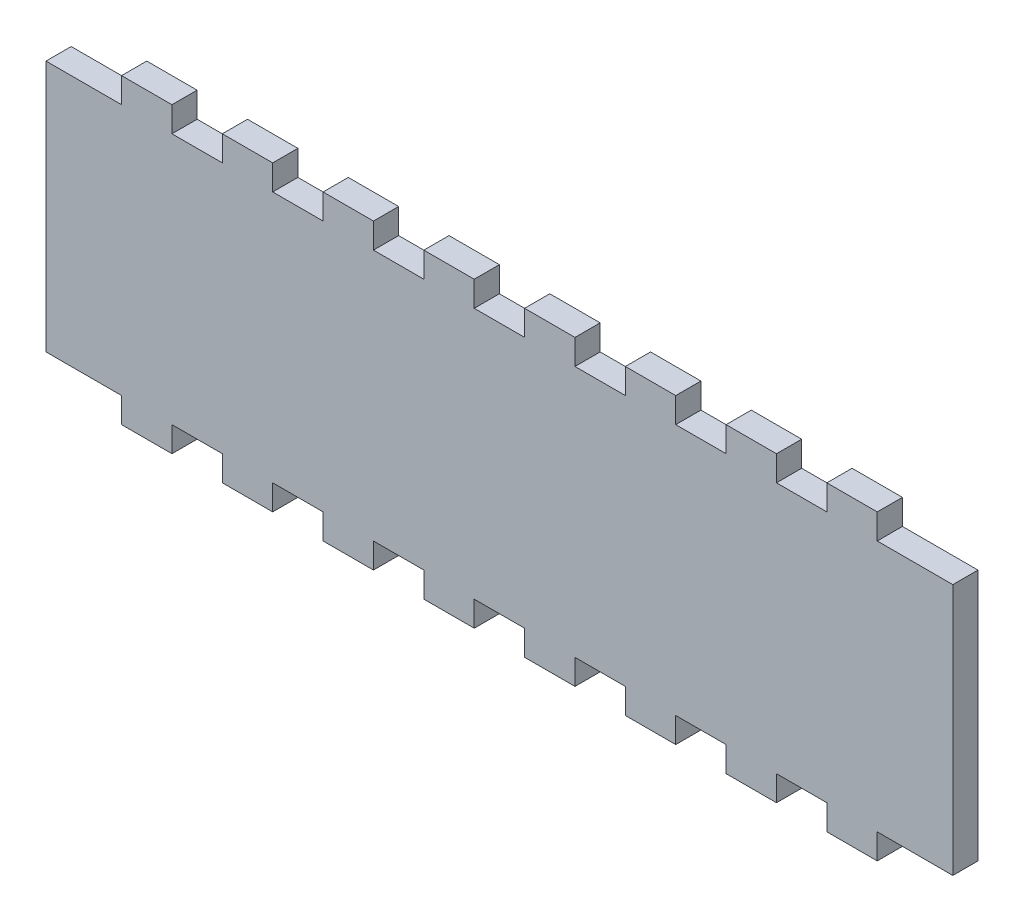
from build123d import *

# Parameters (mm, degrees)
BOSS_EXTRUDE2_DEPTH = 5


with BuildPart() as part:
    # Sketch1 → Boss-Extrude2 (new body)
    with BuildSketch(Plane.XY):
        Polygon((0, 0), (15, 0), (15, -5), (25, -5), (25, 0), (35, 0), (35, -5), (45, -5), (45, 0), (55, 0), (55, -5), (65, -5), (65, 0), (75, 0), (75, -5), (85, -5), (85, 0), (95, 0), (95, -5), (105, -5), (105, 0), (115, 0), (115, -5), (125, -5), (125, 0), (135, 0), (135, -5), (145, -5), (145, 0), (155, 0), (155, -5), (165, -5), (165, 0), (180, 0), (180, 50), (165, 50), (165, 55), (155, 55), (155, 50), (145, 50), (145, 55), (135, 55), (135, 50), (125, 50), (125, 55), (115, 55), (115, 50), (105, 50), (105, 55), (95, 55), (95, 50), (85, 50), (85, 55), (75, 55), (75, 50), (65, 50), (65, 55), (55, 55), (55, 50), (45, 50), (45, 55), (35, 55), (35, 50), (25, 50), (25, 55), (15, 55), (15, 50), (0, 50), align=None)
    extrude(amount=BOSS_EXTRUDE2_DEPTH)


solid = part.part
